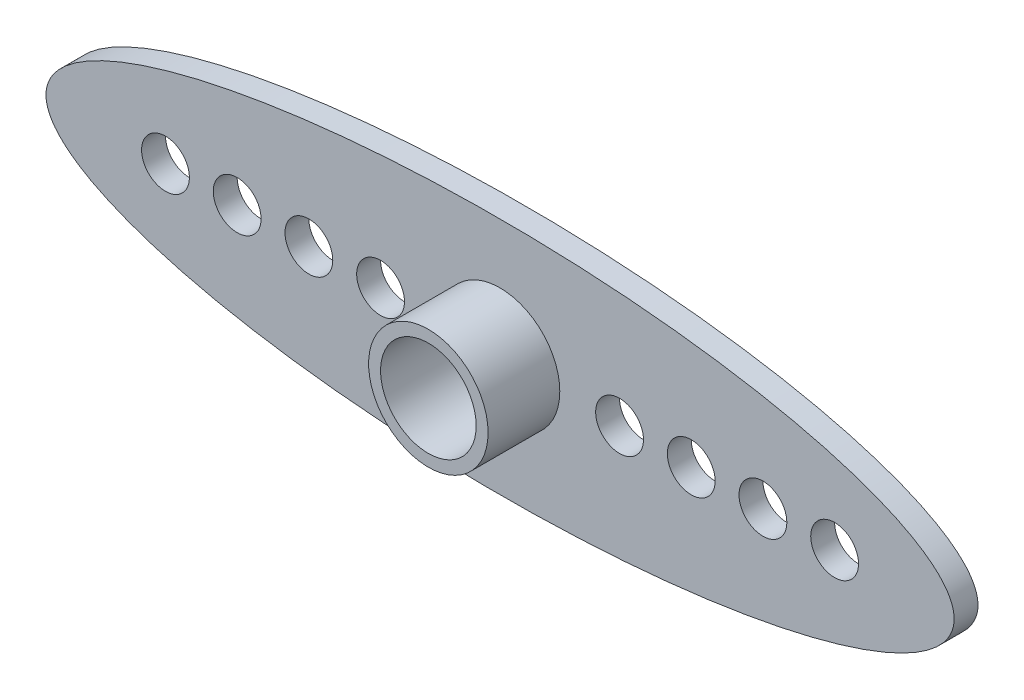
from build123d import *

# Parameters (mm, degrees)
SKETCH_1_RX         = 19
SKETCH_1_RY         = 5
EXTRUDE_1_DEPTH     = 1
SKETCH_2_R          = 2.5
EXTRUDE_2_DEPTH     = 3
SKETCH_3_R          = 1
CUT_EXTRUDE_1_DEPTH = 5
SKETCH_4_R          = 2
CUT_EXTRUDE_2_DEPTH = 3
SKETCH_5_R          = 1.5
CUT_EXTRUDE_3_DEPTH = 3
SKETCH_6_R          = 2.5
SKETCH_6_R_2        = 2
EXTRUDE_3_DEPTH     = 1


with BuildPart() as part:
    # 스케치1 → 보스-돌출1 (new body)
    with BuildSketch(Plane.XY):
        with Locations(Location((0, 0), (0, 0, 180))):
            Ellipse(SKETCH_1_RX, SKETCH_1_RY)
    extrude(amount=EXTRUDE_1_DEPTH)

    # 스케치2 → 보스-돌출2 (add)
    with BuildSketch(Plane.XY.offset(1)):
        Circle(SKETCH_2_R)
    extrude(amount=EXTRUDE_2_DEPTH)

    # 스케치3 → 컷-돌출1 (cut, through all)
    with BuildSketch(Plane(origin=(0, 0, 0), x_dir=(-1, 0, 0), z_dir=(0, 0, -1))):
        with Locations((-5, 0)):
            Circle(SKETCH_3_R)
        with Locations((-8, 0)):
            Circle(SKETCH_3_R)
        with Locations((-11, 0)):
            Circle(SKETCH_3_R)
        with Locations((-14, 0)):
            Circle(SKETCH_3_R)
        with Locations((14, 0)):
            Circle(SKETCH_3_R)
        with Locations((11, 0)):
            Circle(SKETCH_3_R)
        with Locations((8, 0)):
            Circle(SKETCH_3_R)
        with Locations((5, 0)):
            Circle(SKETCH_3_R)
    extrude(amount=-CUT_EXTRUDE_1_DEPTH, mode=Mode.SUBTRACT)

    # 스케치4 → 컷-돌출2 (cut)
    with BuildSketch(Plane.XY.offset(4)):
        Circle(SKETCH_4_R)
    extrude(amount=-CUT_EXTRUDE_2_DEPTH, mode=Mode.SUBTRACT)

    # 스케치5 → 컷-돌출3 (cut)
    with BuildSketch(Plane(origin=(0, 0, 0), x_dir=(-1, 0, 0), z_dir=(0, 0, -1))):
        Circle(SKETCH_5_R)
    extrude(amount=-CUT_EXTRUDE_3_DEPTH, mode=Mode.SUBTRACT)

    # 스케치6 → 보스-돌출3 (add)
    with BuildSketch(Plane(origin=(0, 0, 0), x_dir=(-1, 0, 0), z_dir=(0, 0, -1))):
        Circle(SKETCH_6_R)
        Circle(SKETCH_6_R_2, mode=Mode.SUBTRACT)
    extrude(amount=EXTRUDE_3_DEPTH)


solid = part.part
